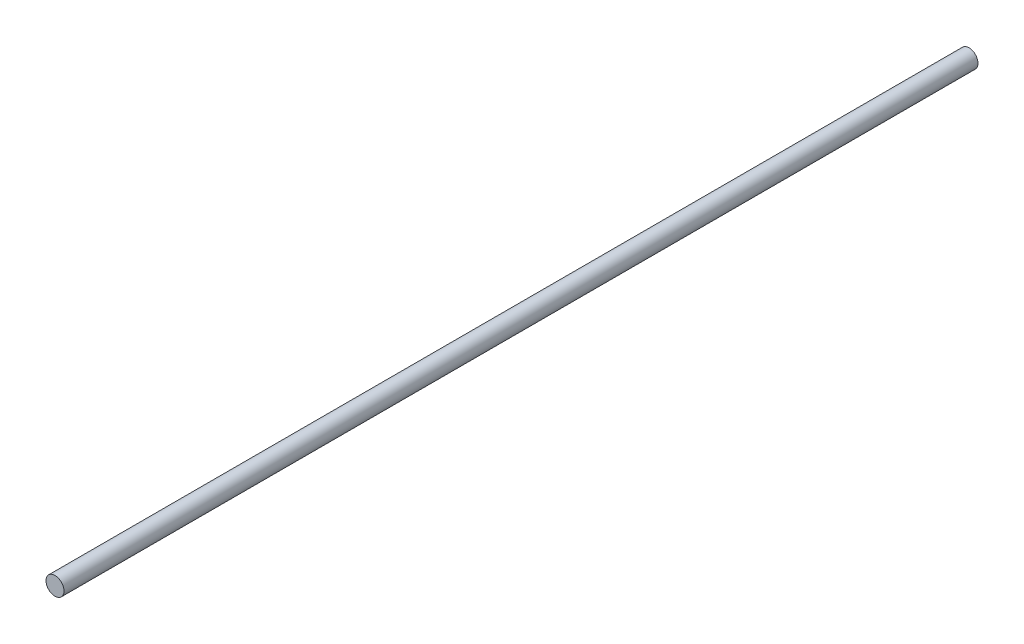
from build123d import *

# Parameters (mm, degrees)
SKETCH1_R           = 4
BOSS_EXTRUDE1_DEPTH = 406


with BuildPart() as part:
    # Sketch1 → Boss-Extrude1 (new body)
    with BuildSketch(Plane.XY):
        Circle(SKETCH1_R)
    extrude(amount=BOSS_EXTRUDE1_DEPTH)


solid = part.part
